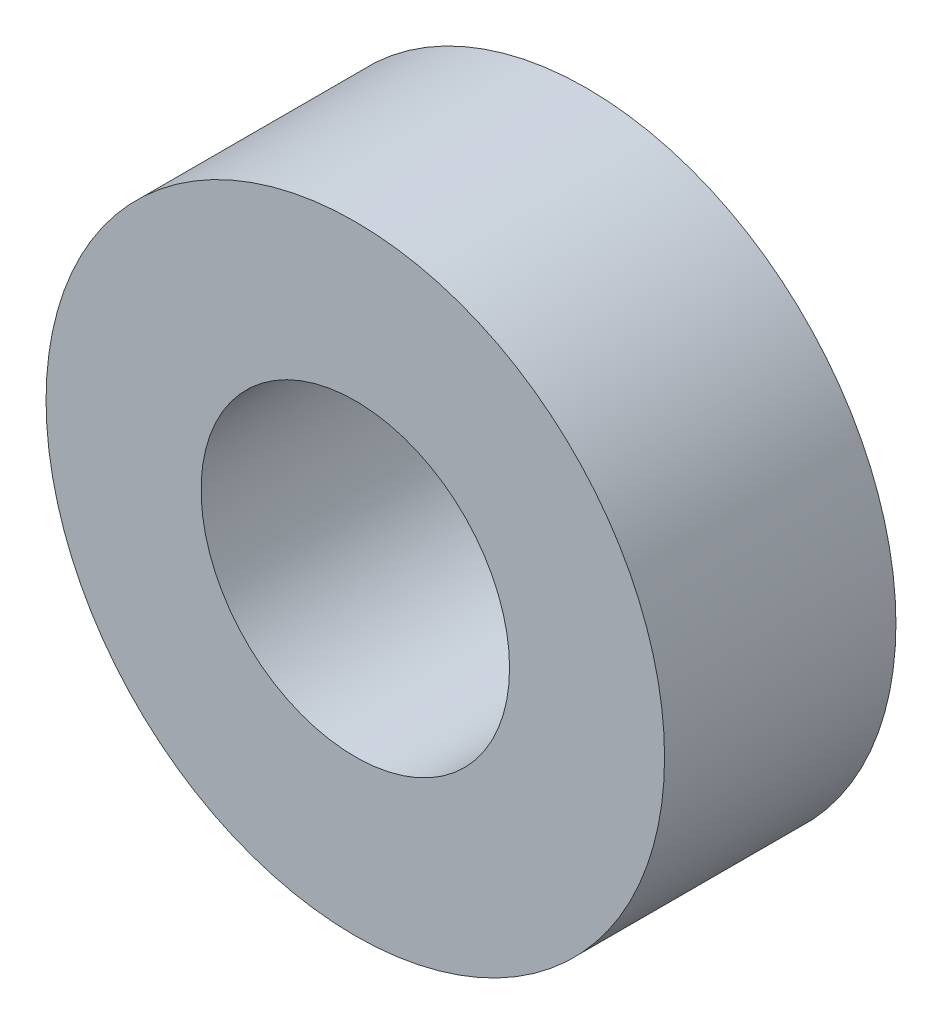
from build123d import *

# Parameters (mm, degrees)
SKETCH1_R      = 4.01
SKETCH1_R_2    = 2
EXTRUDE1_DEPTH = 1.5


with BuildPart() as part:
    # Sketch1 → Extrude1 (new body, symmetric)
    with BuildSketch(Plane.XY):
        Circle(SKETCH1_R)
        Circle(SKETCH1_R_2, mode=Mode.SUBTRACT)
    extrude(amount=EXTRUDE1_DEPTH, both=True)


solid = part.part
